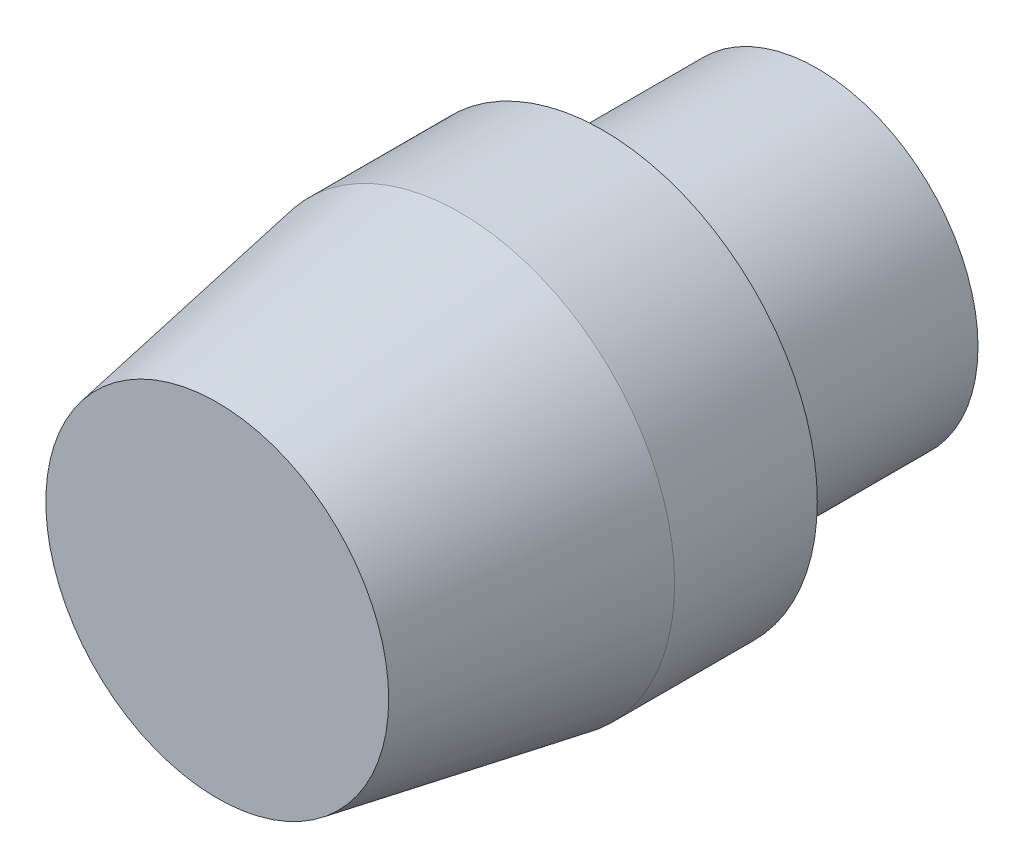
from build123d import *

# Parameters (mm, degrees)
SKETCH1_R           = 7.5
BOSS_EXTRUDE1_DEPTH = 10
SKETCH2_R           = 10
BOSS_EXTRUDE2_DEPTH = 18
CHAMFER1_SIZE       = 2
CHAMFER1_SIZE2      = 11.342563639


with BuildPart() as part:
    # Sketch1 → Boss-Extrude1 (new body)
    with BuildSketch(Plane.XY):
        Circle(SKETCH1_R)
    extrude(amount=BOSS_EXTRUDE1_DEPTH)

    # Sketch2 → Boss-Extrude2 (add)
    with BuildSketch(Plane.XY.offset(10)):
        Circle(SKETCH2_R)
    extrude(amount=BOSS_EXTRUDE2_DEPTH)

    # Chamfer1
    chamfer1_edges = [part.edges().sort_by_distance(p)[0] for p in [
        (-10, 0, 28),
    ]]
    chamfer1_side = [part.faces().sort_by_distance(p)[0] for p in [
        (0, 0, 28),
    ]]
    chamfer(chamfer1_edges, length=CHAMFER1_SIZE, length2=CHAMFER1_SIZE2, reference=chamfer1_side[0])


solid = part.part
